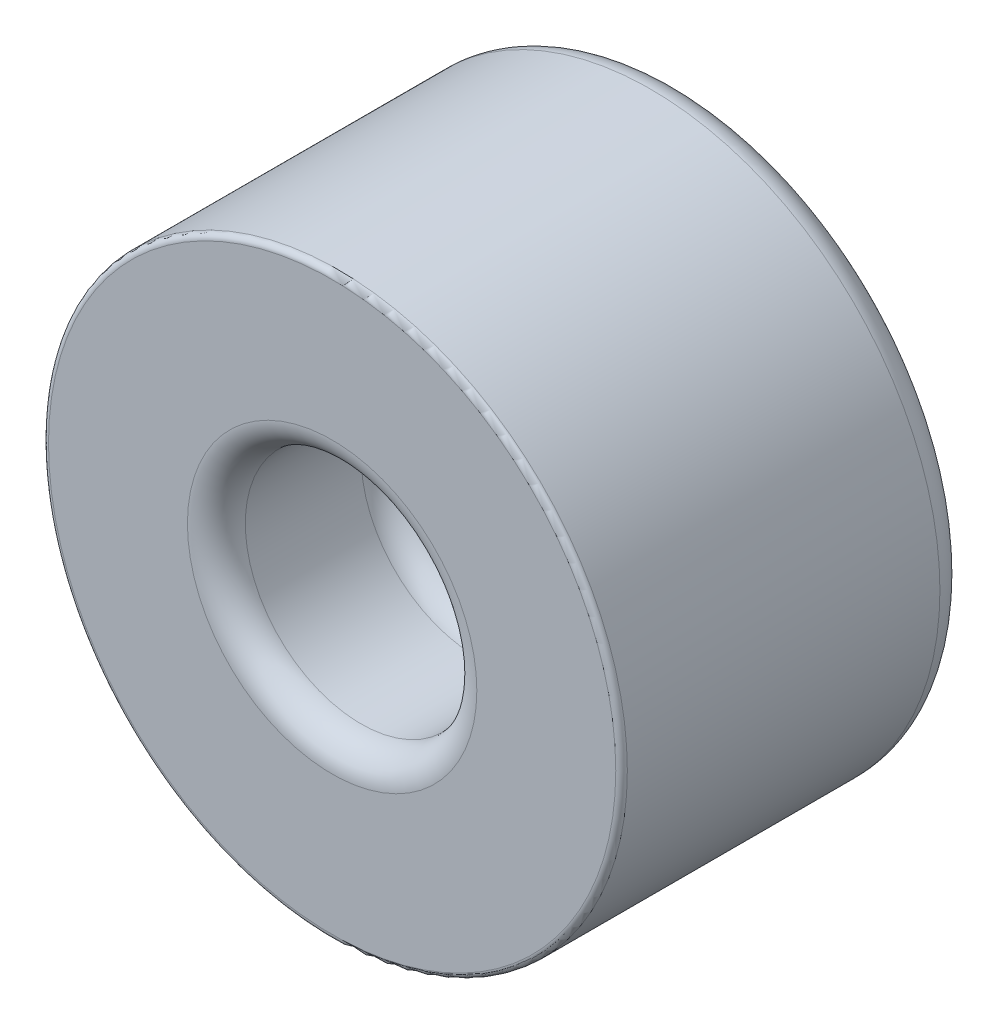
from build123d import *

# Parameters (mm, degrees)
SCHIZZO1_R                   = 5
ESTRUSIONE_ESTRUSIONE1_DEPTH = 6
SCHIZZO2_R                   = 2
TAGLIO_ESTRUSIONE1_DEPTH     = 3
RACCORDO1_R                  = 0.5
RACCORDO2_R                  = 0.1


with BuildPart() as part:
    # Schizzo1 → Estrusione-Estrusione1 (new body)
    with BuildSketch(Plane.XY):
        Circle(SCHIZZO1_R)
    extrude(amount=ESTRUSIONE_ESTRUSIONE1_DEPTH)

    # Schizzo2 → Taglio-Estrusione1 (cut)
    with BuildSketch(Plane.XY.offset(6)):
        Circle(SCHIZZO2_R)
    extrude(amount=-TAGLIO_ESTRUSIONE1_DEPTH, mode=Mode.SUBTRACT)

    # Raccordo1
    raccordo1_edges = [part.edges().sort_by_distance(p)[0] for p in [
        (-5, 0, 0),
        (-2, 0, 3),
        (-2, 0, 6),
    ]]
    fillet(raccordo1_edges, radius=RACCORDO1_R)

    # Raccordo2
    raccordo2_edges = [part.edges().sort_by_distance(p)[0] for p in [
        (-5, 0, 6),
    ]]
    fillet(raccordo2_edges, radius=RACCORDO2_R)


solid = part.part
